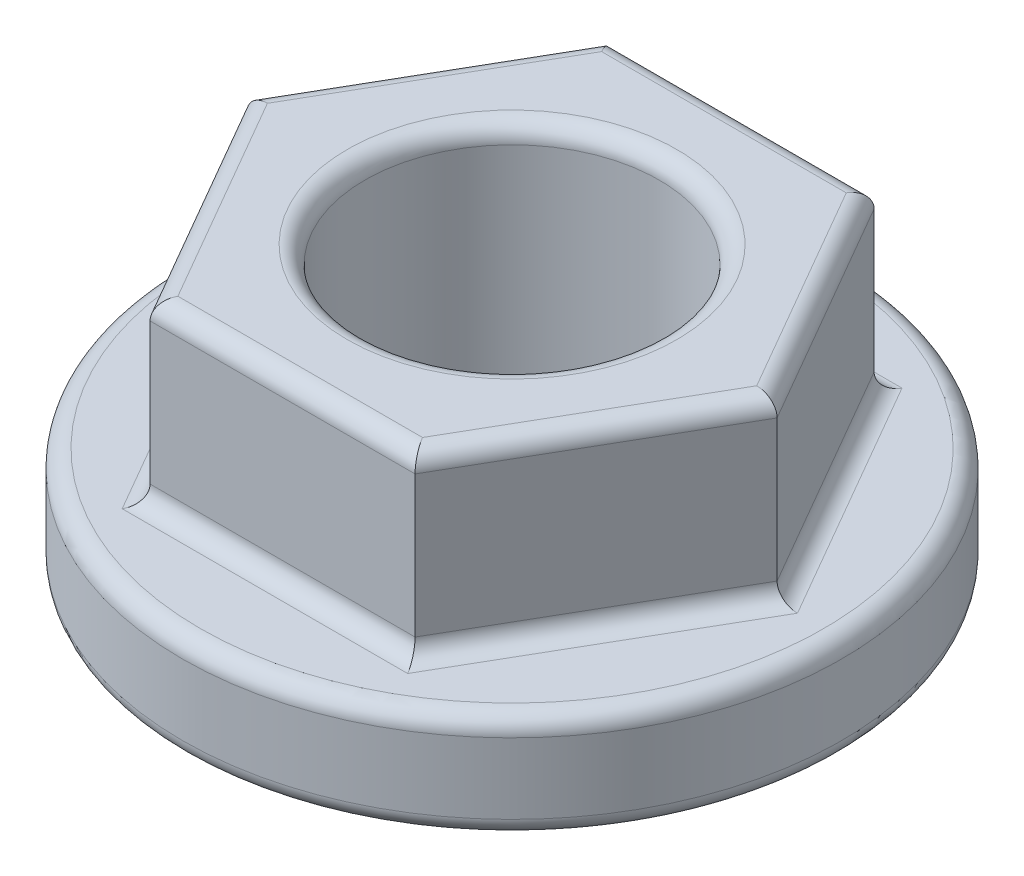
from build123d import *

# Parameters (mm, degrees)
SKETCH1_R           = 5.6
BOSS_EXTRUDE1_DEPTH = 4.8
SKETCH2_R           = 2.5
CUT_EXTRUDE1_DEPTH  = 4.8
SKETCH3_OUTSIDE_W   = 16.51
SKETCH3_OUTSIDE_H   = 16.51
CUT_EXTRUDE2_DEPTH  = 3
FILLET1_R           = 0.3


with BuildPart() as part:
    # Sketch1 → Boss-Extrude1 (new body)
    with BuildSketch(Plane(origin=(0, 0, 0), x_dir=(1, 0, 0), z_dir=(0, 1, 0))):
        Circle(SKETCH1_R)
    extrude(amount=BOSS_EXTRUDE1_DEPTH)

    # Sketch2 → Cut-Extrude1 (cut)
    with BuildSketch(Plane(origin=(0, 4.8, 0), x_dir=(1, 0, 0), z_dir=(0, 1, 0))):
        Circle(SKETCH2_R)
    extrude(amount=-CUT_EXTRUDE1_DEPTH, mode=Mode.SUBTRACT)

    # Sketch3 outside → Cut-Extrude2 (cut)
    with BuildSketch(Plane(origin=(0, 4.8, 0), x_dir=(1, 0, 0), z_dir=(0, 1, 0))):
        Rectangle(SKETCH3_OUTSIDE_W, SKETCH3_OUTSIDE_H)
        Polygon((4.5033321, 0), (2.25166605, 3.9), (-2.25166605, 3.9), (-4.5033321, 0), (-2.25166605, -3.9), (2.25166605, -3.9), align=None, mode=Mode.SUBTRACT)
    extrude(amount=-CUT_EXTRUDE2_DEPTH, mode=Mode.SUBTRACT)

    # Fillet1
    fillet1_edges = [part.edges().sort_by_distance(p)[0] for p in [
        (0, 1.8, 3.9),
        (3.377499075, 1.8, 1.95),
        (3.377499075, 1.8, -1.95),
        (0, 1.8, -3.9),
        (-3.377499075, 1.8, -1.95),
        (-3.377499075, 1.8, 1.95),
        (-5.6, 1.8, 0),
        (-5.6, 0, 0),
        (3.377499075, 4.8, 1.95),
        (0, 4.8, 3.9),
        (-3.377499075, 4.8, 1.95),
        (-3.377499075, 4.8, -1.95),
        (0, 4.8, -3.9),
        (3.377499075, 4.8, -1.95),
        (-2.5, 0, 0),
        (-2.5, 4.8, 0),
    ]]
    fillet(fillet1_edges, radius=FILLET1_R)


solid = part.part
